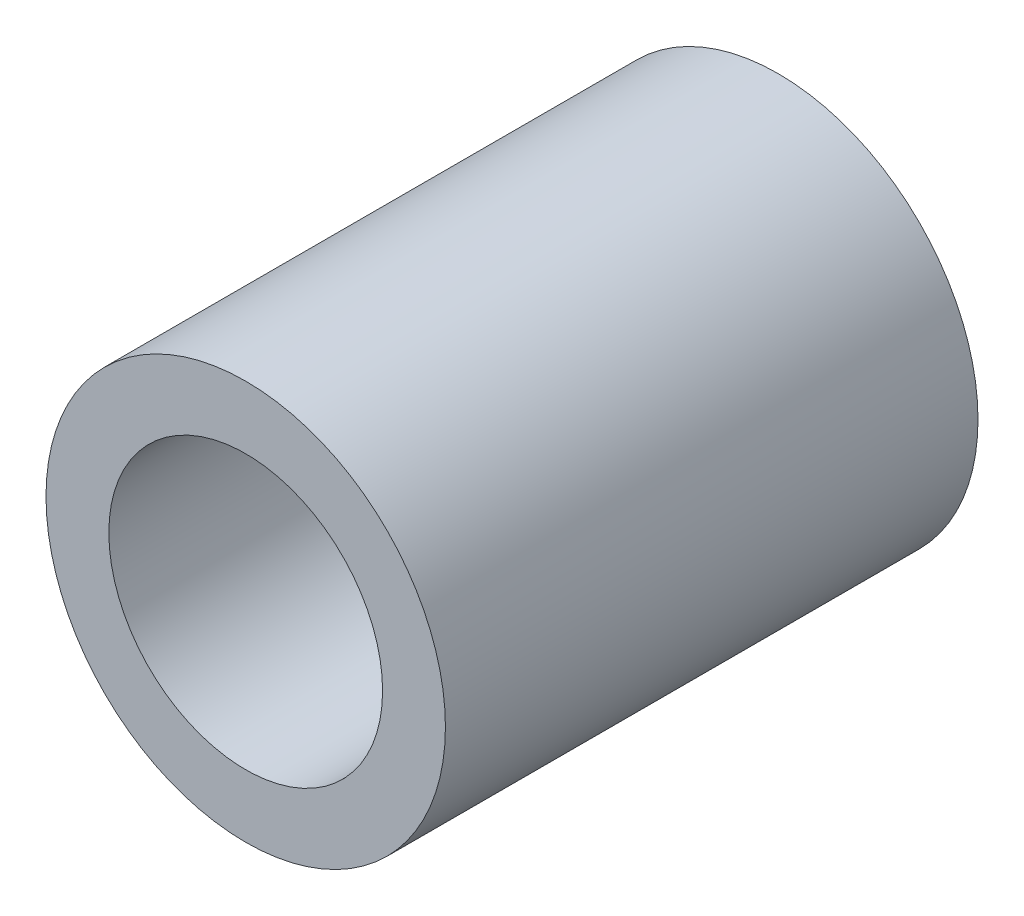
from build123d import *

# Parameters (mm, degrees)
SKETCH1_R                 = 2.38125
EXTRUDE1_DEPTH            = 3.175
F_4_CLEARANCE_HOLE1_D     = 3.2639
F_4_CLEARANCE_HOLE1_DEPTH = 6.35
F_4_CLEARANCE_HOLE1_TIP   = 0.980574487


with BuildPart() as part:
    # Sketch1 → Extrude1 (new body, symmetric)
    with BuildSketch(Plane.XY):
        Circle(SKETCH1_R)
    extrude(amount=EXTRUDE1_DEPTH, both=True)

    # #4 Clearance Hole1
    with Locations(Plane.XY.offset(3.175)):
        with Locations((0, 0)):
            Hole(F_4_CLEARANCE_HOLE1_D / 2, depth=F_4_CLEARANCE_HOLE1_DEPTH)
            with Locations((0, 0, -(F_4_CLEARANCE_HOLE1_DEPTH + F_4_CLEARANCE_HOLE1_TIP / 2))):  # 118° drill point
                Cone(0, F_4_CLEARANCE_HOLE1_D / 2, F_4_CLEARANCE_HOLE1_TIP, mode=Mode.SUBTRACT)


solid = part.part
